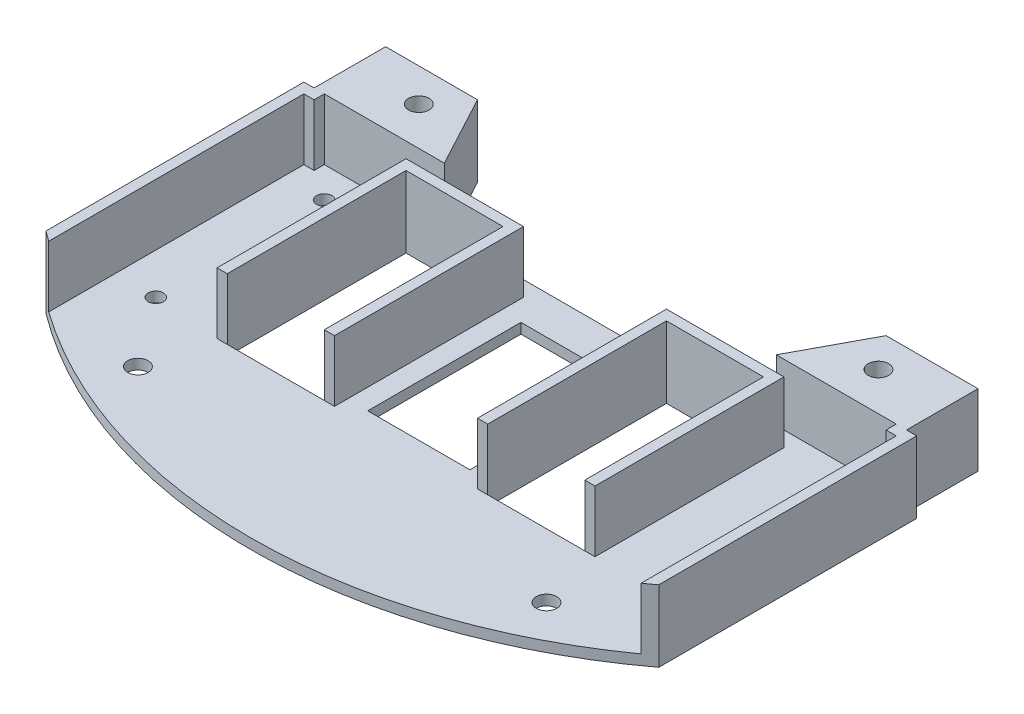
from build123d import *

# Parameters (mm, degrees)
SKETCH_1_W                  = 116
SKETCH_1_H                  = 14
EXTRUDE_763_DEPTH           = 2
CUT_EXTRUDE_1069_DEPTH      = 2
SKETCH_5_W                  = 19
SKETCH_5_H                  = 35
SKETCH_5_W_2                = 20
SKETCH_5_H_2                = 30
CUT_EXTRUDE_1759_DEPTH      = 2
EXTRUDE_3355_DEPTH          = 12
SKETCH_7_W                  = 2
SKETCH_7_H                  = 2
EXTRUDE_4350_DEPTH          = 12
SKETCH_2_R                  = 2
SKETCH_2_R_2                = 1.5
CUT_EXTRUDE_5250_DEPTH      = 12
CUT_EXTRUDE_5250_DEPTH_BACK = 2


with BuildPart() as part:
    # 草图1 → Extrude 763 (new body)
    with BuildSketch(Plane(origin=(0, 0, 0), x_dir=(1, 0, 0), z_dir=(0, 1, 0))):
        with BuildLine():
            Line((-60, -29.5), (-60, -80))
            ThreePointArc((-60, -80), (0, -100), (60, -80))
            Line((60, -80), (60, -29.5))
            Line((60, -29.5), (58, -29.5))
            Line((58, -29.5), (-58, -29.5))
            Line((-58, -29.5), (-60, -29.5))
        make_face()
        with Locations((0, -22.5)):
            Rectangle(SKETCH_1_W, SKETCH_1_H)
    extrude(amount=EXTRUDE_763_DEPTH)

    # 草图3 → Cut-Extrude 1069 (cut)
    with BuildSketch(Plane(origin=(0, 2, 0), x_dir=(1, 0, 0), z_dir=(0, 1, 0))):
        Polygon((-40, -15.5), (40, -15.5), (32.5, -29.5), (-32.5, -29.5), align=None)
    extrude(amount=-CUT_EXTRUDE_1069_DEPTH, mode=Mode.SUBTRACT)

    # 草图5 → Cut-Extrude 1759 (cut)
    with BuildSketch(Plane(origin=(0, 2, 0), x_dir=(1, 0, 0), z_dir=(0, 1, 0))):
        with Locations((-25.5, -52)):
            Rectangle(SKETCH_5_W, SKETCH_5_H)
        with Locations((25.5, -52)):
            Rectangle(SKETCH_5_W, SKETCH_5_H)
        with Locations((0, -52)):
            Rectangle(SKETCH_5_W_2, SKETCH_5_H_2)
    extrude(amount=-CUT_EXTRUDE_1759_DEPTH, mode=Mode.SUBTRACT)

    # 草图6 → Extrude 3355 (add)
    with BuildSketch(Plane(origin=(0, 2, 0), x_dir=(1, 0, 0), z_dir=(0, 1, 0))):
        with BuildLine():
            Line((-58, -81.461647418), (-58, -29.5))
            Line((-58, -29.5), (-60, -29.5))
            Line((-60, -29.5), (-60, -80))
            ThreePointArc((-60, -80), (-59.004526125, -80.737016893), (-58, -81.461647418))
        make_face()
        with BuildLine():
            Line((60, -29.5), (58, -29.5))
            Line((58, -29.5), (58, -81.461647418))
            ThreePointArc((58, -81.461647418), (59.004526125, -80.737016893), (60, -80))
            Line((60, -80), (60, -29.5))
        make_face()
        Polygon((-37, -32.5), (-37, -69.5), (-35, -69.5), (-35, -34.5), (-16, -34.5), (-16, -69.5), (-14, -69.5), (-14, -32.5), align=None)
        Polygon((35, -69.5), (37, -69.5), (37, -32.5), (14, -32.5), (14, -69.5), (16, -69.5), (16, -34.5), (35, -34.5), align=None)
    extrude(amount=EXTRUDE_3355_DEPTH)

    # 草图7 → Extrude 4350 (add)
    with BuildSketch(Plane(origin=(0, 2, 0), x_dir=(1, 0, 0), z_dir=(0, 1, 0))):
        with Locations((-57, -30.5)):
            Rectangle(SKETCH_7_W, SKETCH_7_H)
        Polygon((-32.5, -29.5), (-58, -29.5), (-58, -15.5), (-40, -15.5), align=None)
        with Locations((57, -30.5)):
            Rectangle(SKETCH_7_W, SKETCH_7_H)
        Polygon((32.5, -29.5), (58, -29.5), (58, -15.5), (40, -15.5), align=None)
    extrude(amount=EXTRUDE_4350_DEPTH)

    # 草图2 → Cut-Extrude 5250 (cut, two sides)
    with BuildSketch(Plane(origin=(0, 2, 0), x_dir=(1, 0, 0), z_dir=(0, 1, 0))) as cut_extrude_5250_sk:
        with Locations((-45, -22)):
            Circle(SKETCH_2_R)
        with Locations((-40, -82)):
            Circle(SKETCH_2_R)
        with Locations((40, -82)):
            Circle(SKETCH_2_R)
        with Locations((45, -22)):
            Circle(SKETCH_2_R)
        with Locations((-50, -35.5)):
            Circle(SKETCH_2_R_2)
        with Locations((-50, -68.5)):
            Circle(SKETCH_2_R_2)
        with Locations((50, -68.5)):
            Circle(SKETCH_2_R_2)
        with Locations((50, -35.5)):
            Circle(SKETCH_2_R_2)
    extrude(amount=CUT_EXTRUDE_5250_DEPTH, mode=Mode.SUBTRACT)
    extrude(cut_extrude_5250_sk.sketch, amount=-CUT_EXTRUDE_5250_DEPTH_BACK, mode=Mode.SUBTRACT)


solid = part.part
